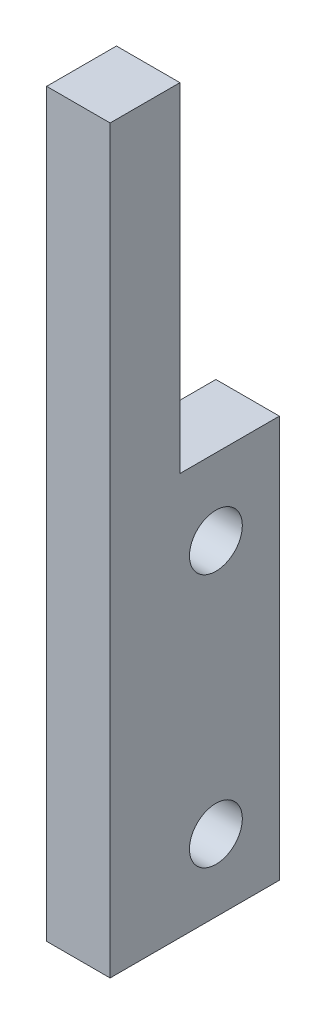
from build123d import *

# Parameters (mm, degrees)
BOSS_EXTRUDE1_DEPTH             = 3
TAP_DRILL_FOR_M3X0_5_TAP1_D     = 2.5
TAP_DRILL_FOR_M3X0_5_TAP1_DEPTH = 3


with BuildPart() as part:
    # Sketch1 → Boss-Extrude1 (new body)
    with BuildSketch(Plane(origin=(0, 0, 0), x_dir=(0, 0, -1), z_dir=(1, 0, 0))):
        Polygon((0, 0), (0, 35), (3.3, 35), (3.3, 19), (8, 19), (8, 0), align=None)
    extrude(amount=BOSS_EXTRUDE1_DEPTH)

    # Tap Drill for M3x0.5 Tap1
    with Locations(Plane(origin=(3, 0, 0), x_dir=(0, 0, -1), z_dir=(1, 0, 0))):
        with Locations((5, 15.4), (5, 3.4)):
            Hole(TAP_DRILL_FOR_M3X0_5_TAP1_D / 2, depth=TAP_DRILL_FOR_M3X0_5_TAP1_DEPTH)


solid = part.part
